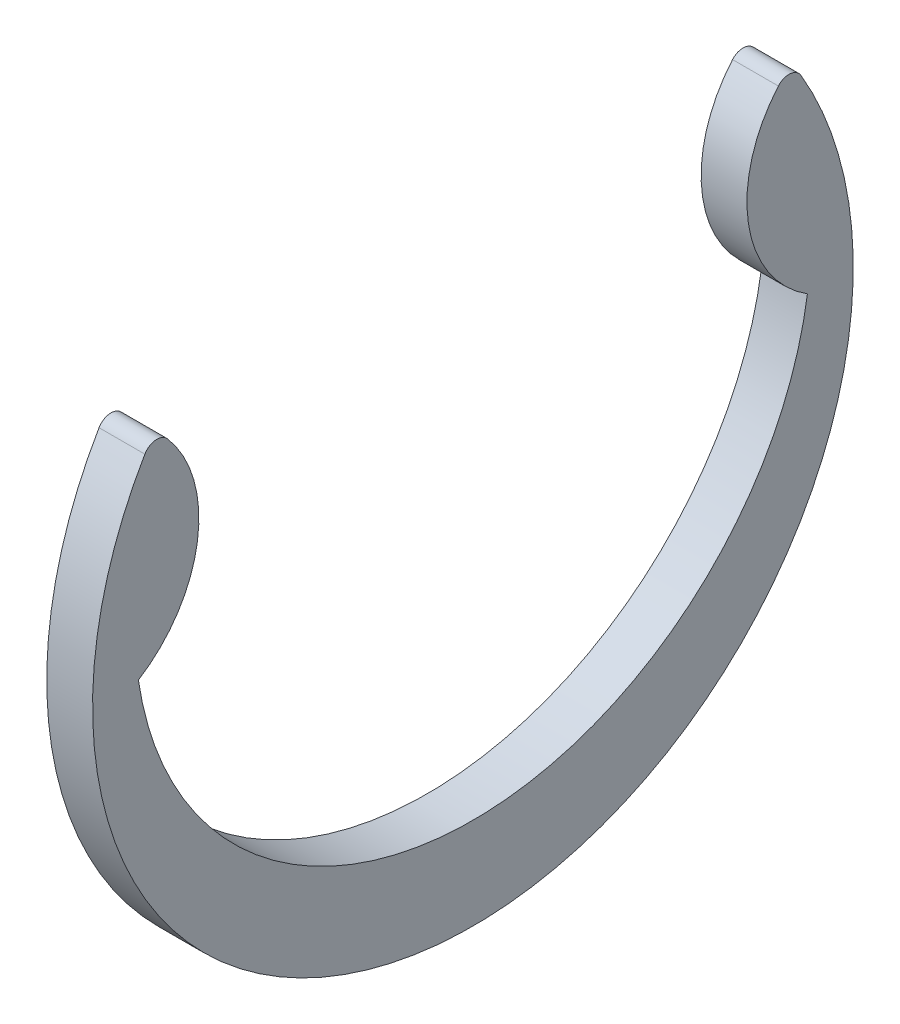
from build123d import *

# Parameters (mm, degrees)
EXTRUDE1_DEPTH = 0.4445


with BuildPart() as part:
    # Sketch1 → Extrude1 (new body, symmetric)
    with BuildSketch(Plane(origin=(0, 0, 0), x_dir=(0, 0, -1), z_dir=(1, 0, 0))):
        with BuildLine():
            ThreePointArc((-6.4897, 0), (0, -5.6007), (6.4897, 0))
            ThreePointArc((6.4897, 0), (5.344056459, 1.757650116), (5.926181677, 3.773329477))
            ThreePointArc((5.926181677, 3.773329477), (6.155394019, 3.866246614), (6.364271463, 3.7338))
            ThreePointArc((6.364271463, 3.7338), (0, -7.3787), (-6.364271463, 3.7338))
            ThreePointArc((-6.364271463, 3.7338), (-6.155394019, 3.866246614), (-5.926181677, 3.773329477))
            ThreePointArc((-5.926181677, 3.773329477), (-5.344056459, 1.757650116), (-6.4897, 0))
        make_face()
    extrude(amount=EXTRUDE1_DEPTH, both=True)


solid = part.part
